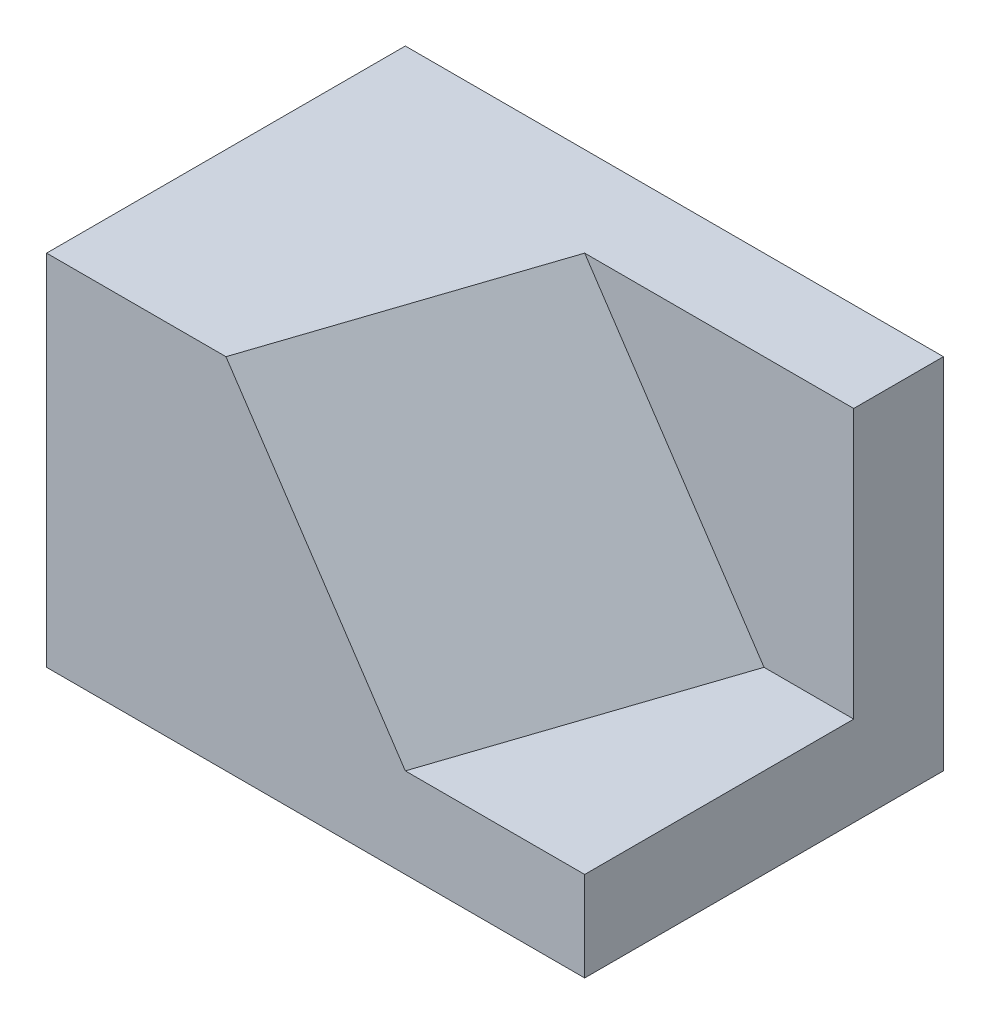
from build123d import *

# Parameters (mm, degrees)
SKETCH_1_W          = 30
SKETCH_1_H          = 20
EXTRUDE_1_DEPTH     = 20
CUT_EXTRUDE_3_REACH = 39.417
SKETCH_5_W          = 15
SKETCH_5_H          = 15


with BuildPart() as part:
    # 草圖1 → 填料-伸長1 (new body)
    with BuildSketch(Plane(origin=(0, 0, 0), x_dir=(1, 0, 0), z_dir=(0, 1, 0))):
        Rectangle(SKETCH_1_W, SKETCH_1_H)
    extrude(amount=EXTRUDE_1_DEPTH)

    # 除料-伸長3: up to this plane
    cut_extrude_3_end = Plane(origin=(7.5, 5, 2.5), z_dir=(-0.8017837257372732, -0.5345224838248487, -0.2672612419124243))
    # 草圖5 → 除料-伸長3 (cut, up to the surface)
    with BuildSketch(Plane(origin=(15, 0, 0), x_dir=(0, 0, -1), z_dir=(1, 0, 0)), mode=Mode.PRIVATE) as cut_extrude_3_sk1:
        with Locations((-2.5, 12.5)):
            Rectangle(SKETCH_5_W, SKETCH_5_H)
    cut_extrude_3_tool1 = split(extrude(cut_extrude_3_sk1.sketch, amount=-CUT_EXTRUDE_3_REACH, mode=Mode.PRIVATE), bisect_by=cut_extrude_3_end, keep=Keep.BOTH, mode=Mode.PRIVATE)
    add(cut_extrude_3_tool1.solids().sort_by_distance((15, 12.5, 2.5))[0], mode=Mode.SUBTRACT)


solid = part.part
